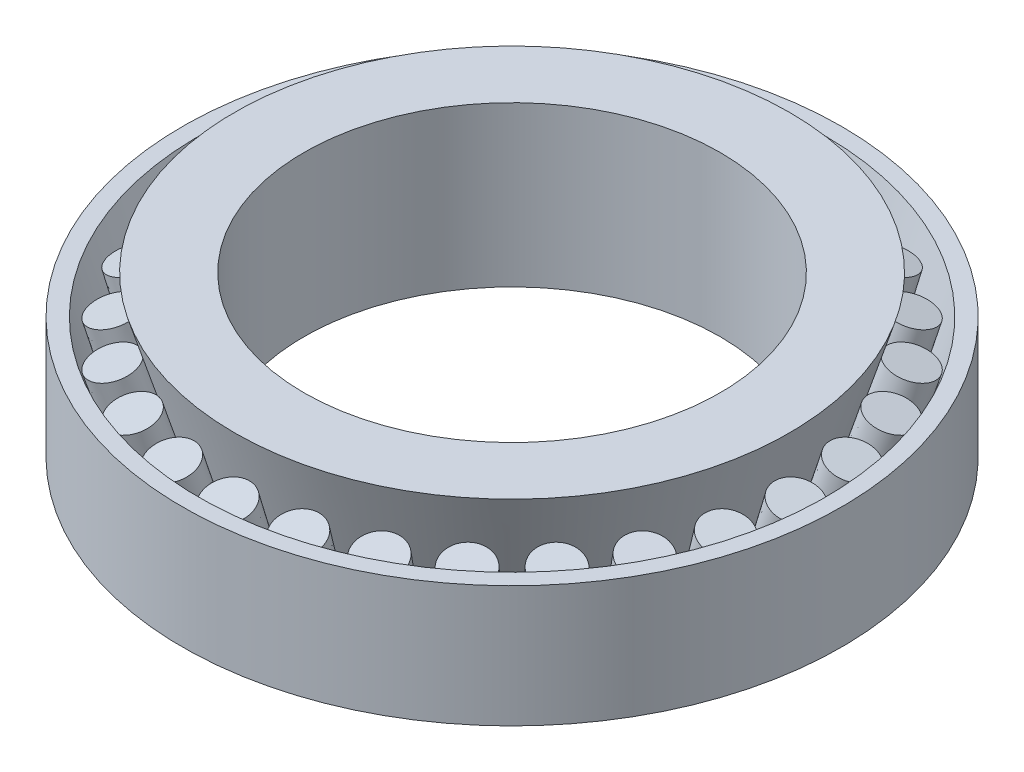
from build123d import *

# Parameters (mm, degrees)
R_P_TITION_CIRCULAIRE1_COUNT = 28


with BuildPart() as part:
    # Esquisse5 → Révolution1 (revolve)
    with BuildSketch(Plane.XY):
        Polygon((-30, 0), (-33, 0), (-40, 23), (-30, 23), align=None)
        Polygon((-47.5, 17.5), (-47.5, 0), (-40, 0), (-45.119286342, 17.5), align=None)
    revolve(axis=Axis((0, 0, 0), (0, 1, 0)))


with BuildPart() as body_2:
    # Esquisse6 → Révolution2 (revolve)
    with BuildSketch(Plane.XY):
        Polygon((-40.978164998, 15.005282288), (-37.850874733, 15.938588409), (-33.667492232, 2.193188761), (-36.869356415, 1.237626857), align=None)
    revolve(axis=Axis((-41.722686649, 17.5, 0), (0.285975498, -0.95823693, 0)))


with BuildPart() as r_p_tition_circulaire1_1:
    # Répétition circulaire1: pattern copy
    add(body_2.part.rotate(Axis((0, 0, 0), (0, 1, 0)), 1 * 360 / R_P_TITION_CIRCULAIRE1_COUNT))


with BuildPart() as r_p_tition_circulaire1_2:
    # Répétition circulaire1: pattern copy
    add(body_2.part.rotate(Axis((0, 0, 0), (0, 1, 0)), 2 * 360 / R_P_TITION_CIRCULAIRE1_COUNT))


with BuildPart() as r_p_tition_circulaire1_3:
    # Répétition circulaire1: pattern copy
    add(body_2.part.rotate(Axis((0, 0, 0), (0, 1, 0)), 3 * 360 / R_P_TITION_CIRCULAIRE1_COUNT))


with BuildPart() as r_p_tition_circulaire1_4:
    # Répétition circulaire1: pattern copy
    add(body_2.part.rotate(Axis((0, 0, 0), (0, 1, 0)), 4 * 360 / R_P_TITION_CIRCULAIRE1_COUNT))


with BuildPart() as r_p_tition_circulaire1_5:
    # Répétition circulaire1: pattern copy
    add(body_2.part.rotate(Axis((0, 0, 0), (0, 1, 0)), 5 * 360 / R_P_TITION_CIRCULAIRE1_COUNT))


with BuildPart() as r_p_tition_circulaire1_6:
    # Répétition circulaire1: pattern copy
    add(body_2.part.rotate(Axis((0, 0, 0), (0, 1, 0)), 6 * 360 / R_P_TITION_CIRCULAIRE1_COUNT))


with BuildPart() as r_p_tition_circulaire1_7:
    # Répétition circulaire1: pattern copy
    add(body_2.part.rotate(Axis((0, 0, 0), (0, 1, 0)), 7 * 360 / R_P_TITION_CIRCULAIRE1_COUNT))


with BuildPart() as r_p_tition_circulaire1_8:
    # Répétition circulaire1: pattern copy
    add(body_2.part.rotate(Axis((0, 0, 0), (0, 1, 0)), 8 * 360 / R_P_TITION_CIRCULAIRE1_COUNT))


with BuildPart() as r_p_tition_circulaire1_9:
    # Répétition circulaire1: pattern copy
    add(body_2.part.rotate(Axis((0, 0, 0), (0, 1, 0)), 9 * 360 / R_P_TITION_CIRCULAIRE1_COUNT))


with BuildPart() as r_p_tition_circulaire1_10:
    # Répétition circulaire1: pattern copy
    add(body_2.part.rotate(Axis((0, 0, 0), (0, 1, 0)), 10 * 360 / R_P_TITION_CIRCULAIRE1_COUNT))


with BuildPart() as r_p_tition_circulaire1_11:
    # Répétition circulaire1: pattern copy
    add(body_2.part.rotate(Axis((0, 0, 0), (0, 1, 0)), 11 * 360 / R_P_TITION_CIRCULAIRE1_COUNT))


with BuildPart() as r_p_tition_circulaire1_12:
    # Répétition circulaire1: pattern copy
    add(body_2.part.rotate(Axis((0, 0, 0), (0, 1, 0)), 12 * 360 / R_P_TITION_CIRCULAIRE1_COUNT))


with BuildPart() as r_p_tition_circulaire1_13:
    # Répétition circulaire1: pattern copy
    add(body_2.part.rotate(Axis((0, 0, 0), (0, 1, 0)), 13 * 360 / R_P_TITION_CIRCULAIRE1_COUNT))


with BuildPart() as r_p_tition_circulaire1_14:
    # Répétition circulaire1: pattern copy
    add(body_2.part.rotate(Axis((0, 0, 0), (0, 1, 0)), 14 * 360 / R_P_TITION_CIRCULAIRE1_COUNT))


with BuildPart() as r_p_tition_circulaire1_15:
    # Répétition circulaire1: pattern copy
    add(body_2.part.rotate(Axis((0, 0, 0), (0, 1, 0)), 15 * 360 / R_P_TITION_CIRCULAIRE1_COUNT))


with BuildPart() as r_p_tition_circulaire1_16:
    # Répétition circulaire1: pattern copy
    add(body_2.part.rotate(Axis((0, 0, 0), (0, 1, 0)), 16 * 360 / R_P_TITION_CIRCULAIRE1_COUNT))


with BuildPart() as r_p_tition_circulaire1_17:
    # Répétition circulaire1: pattern copy
    add(body_2.part.rotate(Axis((0, 0, 0), (0, 1, 0)), 17 * 360 / R_P_TITION_CIRCULAIRE1_COUNT))


with BuildPart() as r_p_tition_circulaire1_18:
    # Répétition circulaire1: pattern copy
    add(body_2.part.rotate(Axis((0, 0, 0), (0, 1, 0)), 18 * 360 / R_P_TITION_CIRCULAIRE1_COUNT))


with BuildPart() as r_p_tition_circulaire1_19:
    # Répétition circulaire1: pattern copy
    add(body_2.part.rotate(Axis((0, 0, 0), (0, 1, 0)), 19 * 360 / R_P_TITION_CIRCULAIRE1_COUNT))


with BuildPart() as r_p_tition_circulaire1_20:
    # Répétition circulaire1: pattern copy
    add(body_2.part.rotate(Axis((0, 0, 0), (0, 1, 0)), 20 * 360 / R_P_TITION_CIRCULAIRE1_COUNT))


with BuildPart() as r_p_tition_circulaire1_21:
    # Répétition circulaire1: pattern copy
    add(body_2.part.rotate(Axis((0, 0, 0), (0, 1, 0)), 21 * 360 / R_P_TITION_CIRCULAIRE1_COUNT))


with BuildPart() as r_p_tition_circulaire1_22:
    # Répétition circulaire1: pattern copy
    add(body_2.part.rotate(Axis((0, 0, 0), (0, 1, 0)), 22 * 360 / R_P_TITION_CIRCULAIRE1_COUNT))


with BuildPart() as r_p_tition_circulaire1_23:
    # Répétition circulaire1: pattern copy
    add(body_2.part.rotate(Axis((0, 0, 0), (0, 1, 0)), 23 * 360 / R_P_TITION_CIRCULAIRE1_COUNT))


with BuildPart() as r_p_tition_circulaire1_24:
    # Répétition circulaire1: pattern copy
    add(body_2.part.rotate(Axis((0, 0, 0), (0, 1, 0)), 24 * 360 / R_P_TITION_CIRCULAIRE1_COUNT))


with BuildPart() as r_p_tition_circulaire1_25:
    # Répétition circulaire1: pattern copy
    add(body_2.part.rotate(Axis((0, 0, 0), (0, 1, 0)), 25 * 360 / R_P_TITION_CIRCULAIRE1_COUNT))


with BuildPart() as r_p_tition_circulaire1_26:
    # Répétition circulaire1: pattern copy
    add(body_2.part.rotate(Axis((0, 0, 0), (0, 1, 0)), 26 * 360 / R_P_TITION_CIRCULAIRE1_COUNT))


with BuildPart() as r_p_tition_circulaire1_27:
    # Répétition circulaire1: pattern copy
    add(body_2.part.rotate(Axis((0, 0, 0), (0, 1, 0)), 27 * 360 / R_P_TITION_CIRCULAIRE1_COUNT))


solid = Compound([part.part, body_2.part, r_p_tition_circulaire1_1.part, r_p_tition_circulaire1_2.part, r_p_tition_circulaire1_3.part, r_p_tition_circulaire1_4.part, r_p_tition_circulaire1_5.part, r_p_tition_circulaire1_6.part, r_p_tition_circulaire1_7.part, r_p_tition_circulaire1_8.part, r_p_tition_circulaire1_9.part, r_p_tition_circulaire1_10.part, r_p_tition_circulaire1_11.part, r_p_tition_circulaire1_12.part, r_p_tition_circulaire1_13.part, r_p_tition_circulaire1_14.part, r_p_tition_circulaire1_15.part, r_p_tition_circulaire1_16.part, r_p_tition_circulaire1_17.part, r_p_tition_circulaire1_18.part, r_p_tition_circulaire1_19.part, r_p_tition_circulaire1_20.part, r_p_tition_circulaire1_21.part, r_p_tition_circulaire1_22.part, r_p_tition_circulaire1_23.part, r_p_tition_circulaire1_24.part, r_p_tition_circulaire1_25.part, r_p_tition_circulaire1_26.part, r_p_tition_circulaire1_27.part])
